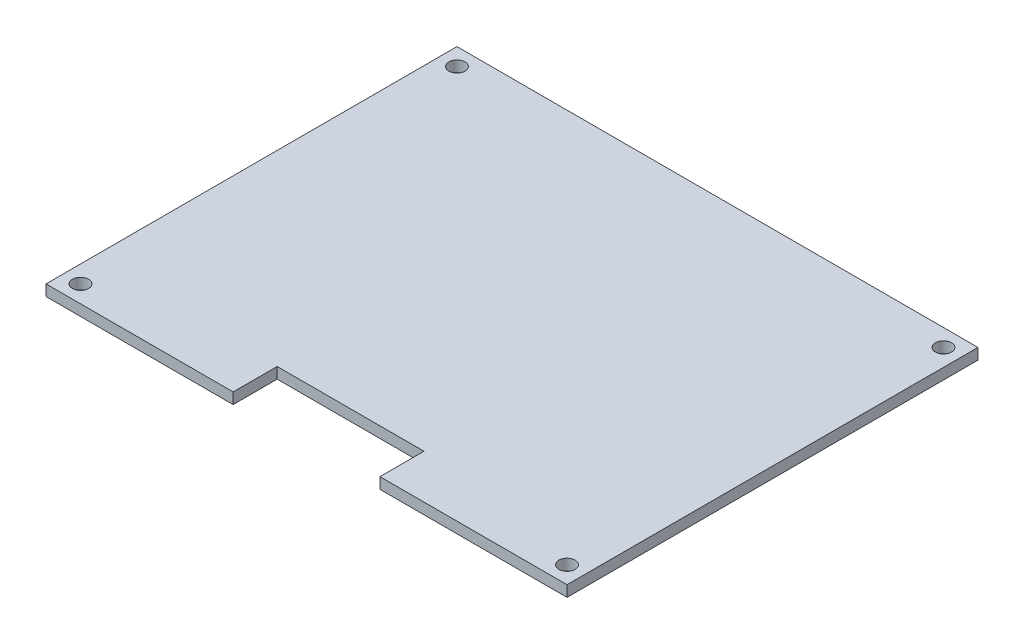
from build123d import *

# Parameters (mm, degrees)
SKETCH1_W           = 71
SKETCH1_H           = 56
BOSS_EXTRUDE1_DEPTH = 1.5
SKETCH2_W           = 20
SKETCH2_H           = 6
CUT_EXTRUDE1_DEPTH  = 1.5
SKETCH5_R           = 1.1
CUT_EXTRUDE2_DEPTH  = 1.5


with BuildPart() as part:
    # Sketch1 → Boss-Extrude1 (new body)
    with BuildSketch(Plane(origin=(0, 0, 0), x_dir=(1, 0, 0), z_dir=(0, 1, 0))):
        with Locations((35.5, 28)):
            Rectangle(SKETCH1_W, SKETCH1_H)
    extrude(amount=BOSS_EXTRUDE1_DEPTH)

    # Sketch2 → Cut-Extrude1 (cut)
    with BuildSketch(Plane(origin=(0, 1.5, 0), x_dir=(1, 0, 0), z_dir=(0, 1, 0))):
        with Locations((35.5, 3)):
            Rectangle(SKETCH2_W, SKETCH2_H)
    extrude(amount=-CUT_EXTRUDE1_DEPTH, mode=Mode.SUBTRACT)

    # Sketch5 → Cut-Extrude2 (cut)
    with BuildSketch(Plane(origin=(0, 1.5, 0), x_dir=(1, 0, 0), z_dir=(0, 1, 0))):
        with Locations((2.35, 53.65)):
            Circle(SKETCH5_R)
        with Locations((68.65, 53.65)):
            Circle(SKETCH5_R)
    cut_extrude2 = extrude(amount=-CUT_EXTRUDE2_DEPTH, mode=Mode.SUBTRACT)

    # Mirror1: Cut-Extrude2 across plane
    add(cut_extrude2.mirror(Plane.XY.offset(-28)), mode=Mode.SUBTRACT)


solid = part.part
